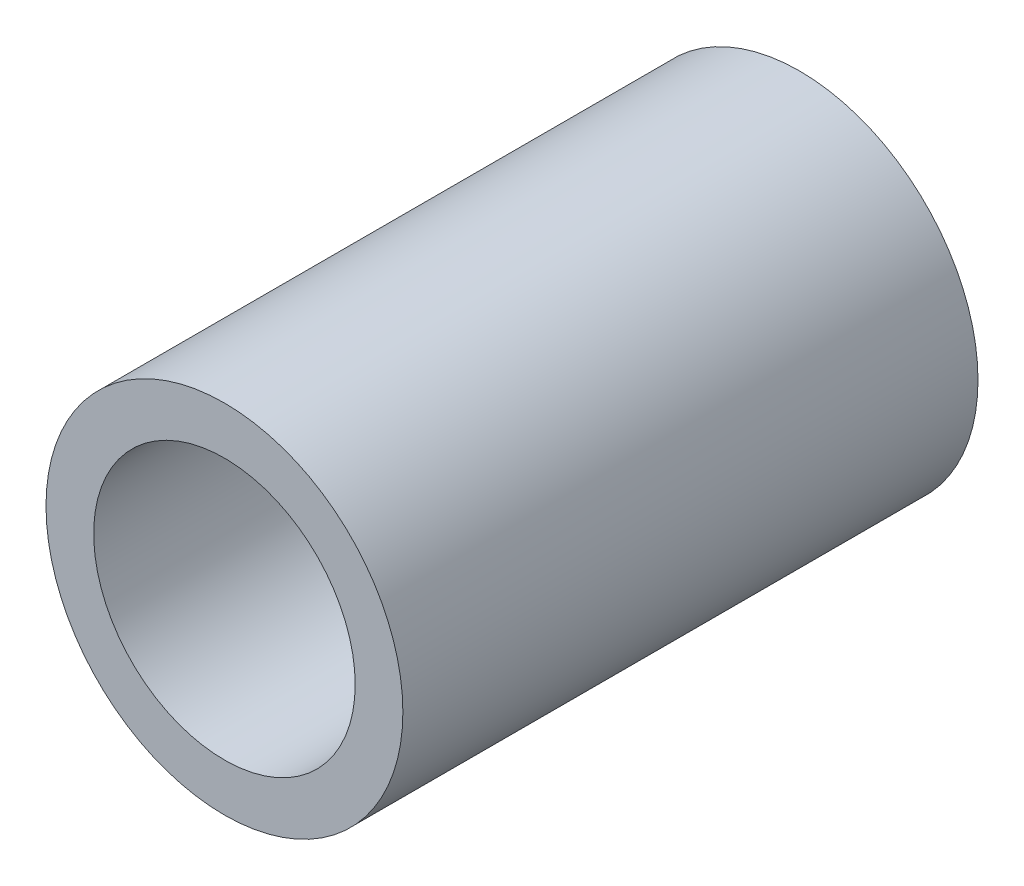
from build123d import *

# Parameters (mm, degrees)
SKETCH1_R                = 4.6101
BOSS_EXTRUDE1_DEPTH      = 14.859
H_0_266_DIAMETER_HOLE1_D = 6.7564


with BuildPart() as part:
    # Sketch1 → Boss-Extrude1 (new body)
    with BuildSketch(Plane.XY):
        Circle(SKETCH1_R)
    extrude(amount=-BOSS_EXTRUDE1_DEPTH)

    # H (0.266) Diameter Hole1 (through all)
    with Locations(Plane.XY):
        with Locations((0, 0)):
            Hole(H_0_266_DIAMETER_HOLE1_D / 2)


solid = part.part
